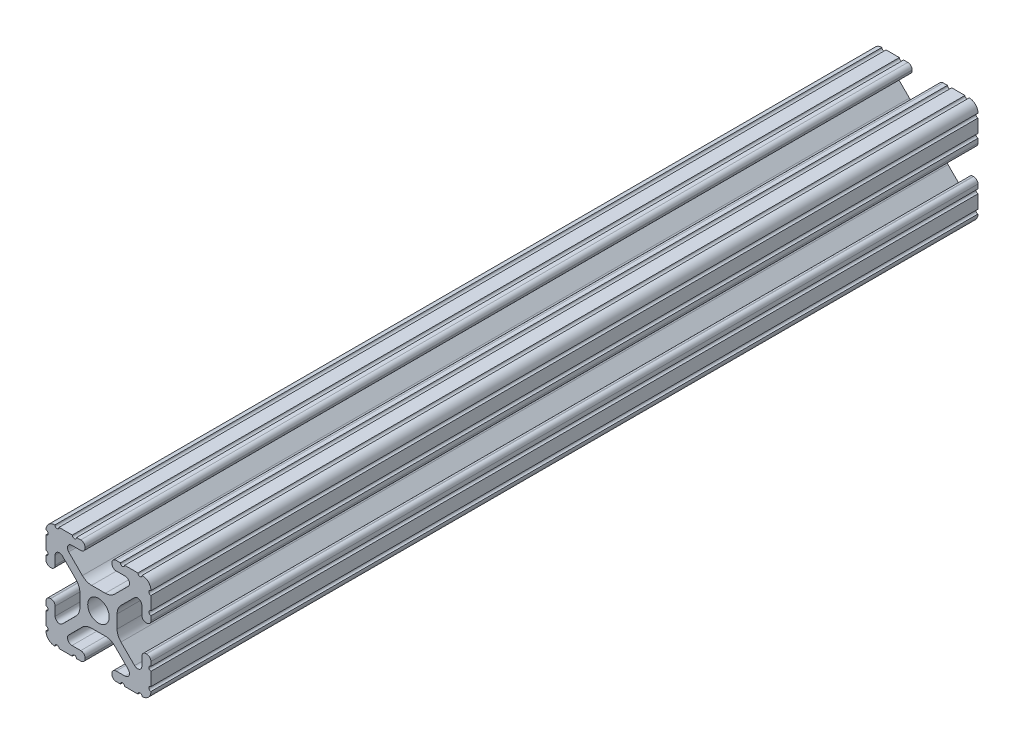
from build123d import *

# Parameters (mm, degrees)
SKETCH1_R               = 2.6035
BOSS_EXTRUDE1_DEPTH     = 457.2
CUT_EXTRUDE2_DEPTH      = 4.318
CUT_EXTRUDE2_DEPTH_BACK = 26.924


with BuildPart() as part:
    # Sketch1 → Boss-Extrude1 (new body, symmetric)
    with BuildSketch(Plane.XY):
        with BuildLine():
            Line((-7.179650497, -8.645192506), (-3.952270251, -5.423690499))
            ThreePointArc((-3.952270251, -5.423690499), (-2.922936451, -4.736929036), (-1.709253557, -4.4958))
            Line((-1.709253557, -4.4958), (1.709253557, -4.4958))
            ThreePointArc((1.709253557, -4.4958), (2.922936451, -4.736929036), (3.952270251, -5.423690499))
            Line((3.952270251, -5.423690499), (7.179650497, -8.645192506))
            ThreePointArc((7.179650497, -8.645192506), (7.41473083, -9.822813117), (6.416408329, -10.4902))
            Line((6.416408329, -10.4902), (4.287512407, -10.4902))
            ThreePointArc((4.287512407, -10.4902), (3.54574862, -10.79744862), (3.2385, -11.539212407))
            Line((3.2385, -11.539212407), (3.2385, -11.650987593))
            ThreePointArc((3.2385, -11.650987593), (3.54574862, -12.39275138), (4.287512407, -12.7))
            Line((4.287512407, -12.7), (5.317126718, -12.7))
            ThreePointArc((5.317126718, -12.7), (5.825126718, -12.192), (6.333126718, -12.7))
            Line((6.333126718, -12.7), (9.550443118, -12.7))
            ThreePointArc((9.550443118, -12.7), (10.058366869, -12.192000006), (10.566443095, -12.699847501))
            ThreePointArc((10.566443095, -12.699847501), (12.082537762, -12.08250727), (12.699846982, -10.566399977))
            ThreePointArc((12.699846982, -10.566399977), (12.192000006, -10.058323491), (12.7, -9.5504))
            Line((12.7, -9.5504), (12.7, -6.3330836))
            ThreePointArc((12.7, -6.3330836), (12.192, -5.8250836), (12.7, -5.3170836))
            Line((12.7, -5.3170836), (12.7, -4.287469289))
            ThreePointArc((12.7, -4.287469289), (12.39275138, -3.545705502), (11.650987593, -3.238456882))
            Line((11.650987593, -3.238456882), (11.539212407, -3.238456882))
            ThreePointArc((11.539212407, -3.238456882), (10.79744862, -3.545705502), (10.4902, -4.287469289))
            Line((10.4902, -4.287469289), (10.4902, -6.402089023))
            ThreePointArc((10.4902, -6.402089023), (9.856505071, -7.351067942), (8.737131347, -7.129408934))
            Line((8.737131347, -7.129408934), (5.441005833, -3.840816462))
            ThreePointArc((5.441005833, -3.840816462), (4.750877967, -2.809883091), (4.5085, -1.593185507))
            Line((4.5085, -1.593185507), (4.5085, 1.593185507))
            ThreePointArc((4.5085, 1.593185507), (4.750877967, 2.809883091), (5.441005833, 3.840816462))
            Line((5.441005833, 3.840816462), (8.737131347, 7.129408934))
            ThreePointArc((8.737131347, 7.129408934), (9.856505071, 7.351067942), (10.4902, 6.402089023))
            Line((10.4902, 6.402089023), (10.4902, 4.287469289))
            ThreePointArc((10.4902, 4.287469289), (10.79744862, 3.545705502), (11.539212407, 3.238456882))
            Line((11.539212407, 3.238456882), (11.650987593, 3.238456882))
            ThreePointArc((11.650987593, 3.238456882), (12.39275138, 3.545705502), (12.7, 4.287469289))
            Line((12.7, 4.287469289), (12.7, 5.3170836))
            ThreePointArc((12.7, 5.3170836), (12.192, 5.8250836), (12.7, 6.3330836))
            Line((12.7, 6.3330836), (12.7, 9.5504))
            ThreePointArc((12.7, 9.5504), (12.192000006, 10.058323491), (12.699846982, 10.566399977))
            ThreePointArc((12.699846982, 10.566399977), (12.082537762, 12.08250727), (10.566443095, 12.699847501))
            ThreePointArc((10.566443095, 12.699847501), (10.058366869, 12.192000006), (9.550443118, 12.7))
            Line((9.550443118, 12.7), (6.333126718, 12.7))
            ThreePointArc((6.333126718, 12.7), (5.825126718, 12.192), (5.317126718, 12.7))
            Line((5.317126718, 12.7), (4.287512407, 12.7))
            ThreePointArc((4.287512407, 12.7), (3.54574862, 12.39275138), (3.2385, 11.650987593))
            Line((3.2385, 11.650987593), (3.2385, 11.539212407))
            ThreePointArc((3.2385, 11.539212407), (3.54574862, 10.79744862), (4.287512407, 10.4902))
            Line((4.287512407, 10.4902), (6.476788598, 10.4902))
            ThreePointArc((6.476788598, 10.4902), (7.432222385, 9.85140422), (7.207036008, 8.724370562))
            Line((7.207036008, 8.724370562), (3.898272566, 5.423169045))
            ThreePointArc((3.898272566, 5.423169045), (2.869120213, 4.736787962), (1.655778399, 4.4958))
            Line((1.655778399, 4.4958), (-1.655778399, 4.4958))
            ThreePointArc((-1.655778399, 4.4958), (-2.869120213, 4.736787962), (-3.898272566, 5.423169045))
            Line((-3.898272566, 5.423169045), (-7.207036008, 8.724370562))
            ThreePointArc((-7.207036008, 8.724370562), (-7.432222385, 9.85140422), (-6.476788598, 10.4902))
            Line((-6.476788598, 10.4902), (-4.287512407, 10.4902))
            ThreePointArc((-4.287512407, 10.4902), (-3.54574862, 10.79744862), (-3.2385, 11.539212407))
            Line((-3.2385, 11.539212407), (-3.2385, 11.650987593))
            ThreePointArc((-3.2385, 11.650987593), (-3.54574862, 12.39275138), (-4.287512407, 12.7))
            Line((-4.287512407, 12.7), (-5.317126718, 12.7))
            ThreePointArc((-5.317126718, 12.7), (-5.825126718, 12.192), (-6.333126718, 12.7))
            Line((-6.333126718, 12.7), (-9.550443118, 12.7))
            ThreePointArc((-9.550443118, 12.7), (-10.058366869, 12.192000006), (-10.566443095, 12.699847501))
            ThreePointArc((-10.566443095, 12.699847501), (-12.082537762, 12.08250727), (-12.699846982, 10.566399977))
            ThreePointArc((-12.699846982, 10.566399977), (-12.192000006, 10.058323491), (-12.7, 9.5504))
            Line((-12.7, 9.5504), (-12.7, 6.3330836))
            ThreePointArc((-12.7, 6.3330836), (-12.192, 5.8250836), (-12.7, 5.3170836))
            Line((-12.7, 5.3170836), (-12.7, 4.287469289))
            ThreePointArc((-12.7, 4.287469289), (-12.39275138, 3.545705502), (-11.650987593, 3.238456882))
            Line((-11.650987593, 3.238456882), (-11.539212407, 3.238456882))
            ThreePointArc((-11.539212407, 3.238456882), (-10.79744862, 3.545705502), (-10.4902, 4.287469289))
            Line((-10.4902, 4.287469289), (-10.4902, 6.402089023))
            ThreePointArc((-10.4902, 6.402089023), (-9.856505071, 7.351067942), (-8.737131347, 7.129408934))
            Line((-8.737131347, 7.129408934), (-5.441005833, 3.840816462))
            ThreePointArc((-5.441005833, 3.840816462), (-4.750877967, 2.809883091), (-4.5085, 1.593185507))
            Line((-4.5085, 1.593185507), (-4.5085, -1.593185507))
            ThreePointArc((-4.5085, -1.593185507), (-4.750877967, -2.809883091), (-5.441005833, -3.840816462))
            Line((-5.441005833, -3.840816462), (-8.737131347, -7.129408934))
            ThreePointArc((-8.737131347, -7.129408934), (-9.856505071, -7.351067942), (-10.4902, -6.402089023))
            Line((-10.4902, -6.402089023), (-10.4902, -4.287469289))
            ThreePointArc((-10.4902, -4.287469289), (-10.79744862, -3.545705502), (-11.539212407, -3.238456882))
            Line((-11.539212407, -3.238456882), (-11.650987593, -3.238456882))
            ThreePointArc((-11.650987593, -3.238456882), (-12.39275138, -3.545705502), (-12.7, -4.287469289))
            Line((-12.7, -4.287469289), (-12.7, -5.3170836))
            ThreePointArc((-12.7, -5.3170836), (-12.192, -5.8250836), (-12.7, -6.3330836))
            Line((-12.7, -6.3330836), (-12.7, -9.5504))
            ThreePointArc((-12.7, -9.5504), (-12.192000006, -10.058323491), (-12.699846982, -10.566399977))
            ThreePointArc((-12.699846982, -10.566399977), (-12.082537762, -12.08250727), (-10.566443095, -12.699847501))
            ThreePointArc((-10.566443095, -12.699847501), (-10.058366869, -12.192000006), (-9.550443118, -12.7))
            Line((-9.550443118, -12.7), (-6.333126718, -12.7))
            ThreePointArc((-6.333126718, -12.7), (-5.825126718, -12.192), (-5.317126718, -12.7))
            Line((-5.317126718, -12.7), (-4.287512407, -12.7))
            ThreePointArc((-4.287512407, -12.7), (-3.54574862, -12.39275138), (-3.2385, -11.650987593))
            Line((-3.2385, -11.650987593), (-3.2385, -11.539212407))
            ThreePointArc((-3.2385, -11.539212407), (-3.54574862, -10.79744862), (-4.287512407, -10.4902))
            Line((-4.287512407, -10.4902), (-6.416408329, -10.4902))
            ThreePointArc((-6.416408329, -10.4902), (-7.41473083, -9.822813117), (-7.179650497, -8.645192506))
        make_face()
        Circle(SKETCH1_R, mode=Mode.SUBTRACT)
    extrude(amount=BOSS_EXTRUDE1_DEPTH, both=True)

    # Sketch3 → Cut-Extrude2 (cut, two sides)
    with BuildSketch(Plane.ZY.offset(12.7)) as cut_extrude2_sk:
        Polygon((-203.2, 21.063041056), (-461.090893327, 21.063041056), (-461.090893327, -25.4), (-203.2, -27.249602883), (257.029766368, -27.249602883), (257.029766368, 21.063041056), align=None)
    extrude(amount=CUT_EXTRUDE2_DEPTH, mode=Mode.SUBTRACT)
    extrude(cut_extrude2_sk.sketch, amount=-CUT_EXTRUDE2_DEPTH_BACK, mode=Mode.SUBTRACT)


solid = part.part
